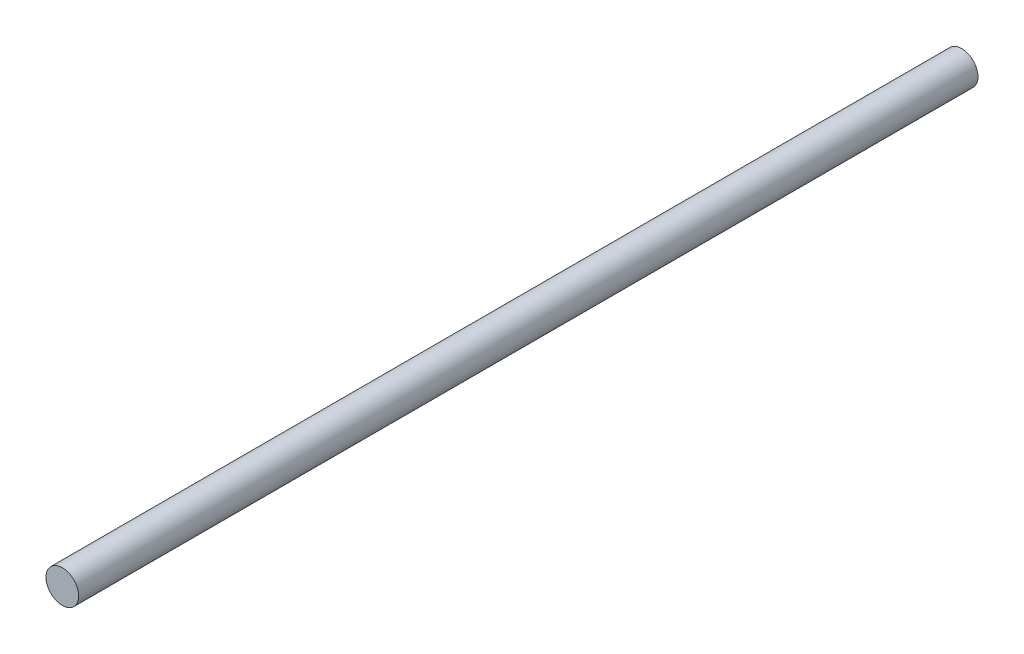
from build123d import *

# Parameters (mm, degrees)
SKETCH1_R           = 0.8
BOSS_EXTRUDE1_DEPTH = 44


with BuildPart() as part:
    # Sketch1 → Boss-Extrude1 (new body)
    with BuildSketch(Plane.XY):
        Circle(SKETCH1_R)
    extrude(amount=BOSS_EXTRUDE1_DEPTH)


solid = part.part
